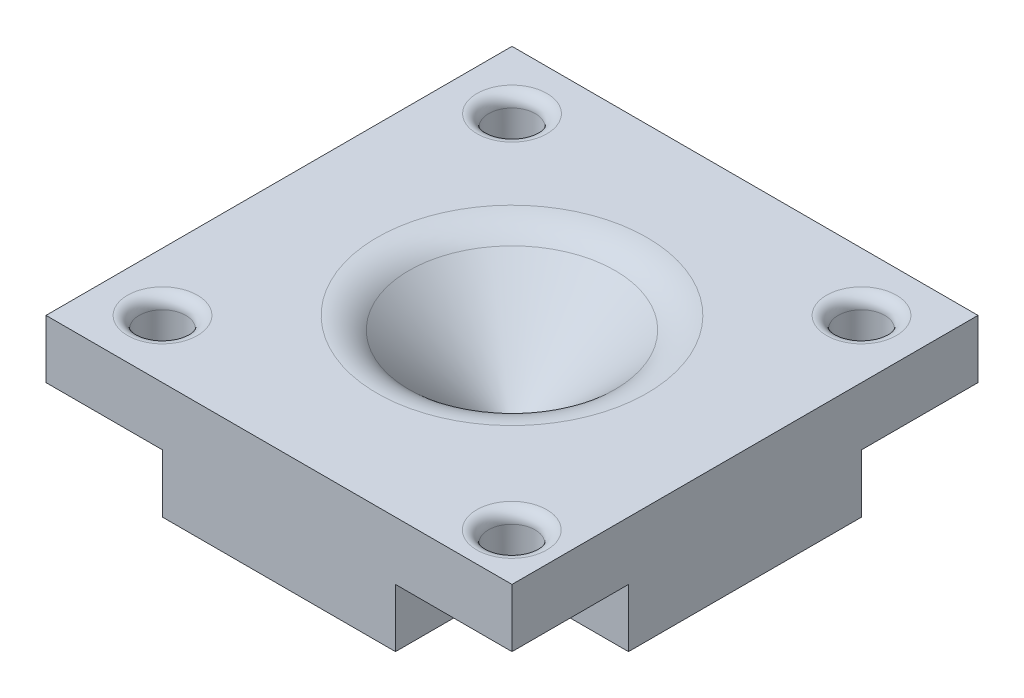
from build123d import *

# Parameters (mm, degrees)
SKETCH1_W           = 20
SKETCH1_H           = 20
BOSS_EXTRUDE1_DEPTH = 5
SKETCH4_W           = 0.5
SKETCH4_H           = 0.5
CUT_EXTRUDE1_DEPTH  = 7
FILLET1_R           = 2
SKETCH5_W           = 5
SKETCH5_H           = 5
CUT_EXTRUDE2_DEPTH  = 2.5
SKETCH6_R           = 1
CUT_EXTRUDE3_DEPTH  = 3
FILLET2_R           = 0.5


with BuildPart() as part:
    # Sketch1 → Boss-Extrude1 (new body)
    with BuildSketch(Plane(origin=(0, 0, 0), x_dir=(1, 0, 0), z_dir=(0, 1, 0))):
        with Locations((10, 10)):
            Rectangle(SKETCH1_W, SKETCH1_H)
    extrude(amount=BOSS_EXTRUDE1_DEPTH)

    # Sketch3 → Cut-Revolve3 (revolve, cut)
    with BuildSketch(Plane(origin=(10, 0, 0), x_dir=(0, 0, -1), z_dir=(1, 0, 0))):
        Polygon((10, 0.3), (10, 5), (5, 5), align=None)
    revolve(axis=Axis((10, 5, -10), (0, -1, 0)), mode=Mode.SUBTRACT)

    # Sketch4 → Cut-Extrude1 (cut)
    with BuildSketch(Plane(origin=(0, 5, 0), x_dir=(1, 0, 0), z_dir=(0, 1, 0))):
        with Locations((10, 10)):
            Rectangle(SKETCH4_W, SKETCH4_H)
    extrude(amount=-CUT_EXTRUDE1_DEPTH, mode=Mode.SUBTRACT)

    # Fillet1
    fillet1_edges = [part.edges().sort_by_distance(p)[0] for p in [
        (10, 5, -15),
    ]]
    fillet(fillet1_edges, radius=FILLET1_R)

    # Sketch5 → Cut-Extrude2 (cut)
    with BuildSketch(Plane(origin=(0, 0, 0), x_dir=(-1, 0, 0), z_dir=(0, -1, 0))):
        with Locations((-17.5, 17.5)):
            Rectangle(SKETCH5_W, SKETCH5_H)
        with Locations((-2.5, 17.5)):
            Rectangle(SKETCH5_W, SKETCH5_H)
        with Locations((-17.5, 2.5)):
            Rectangle(SKETCH5_W, SKETCH5_H)
        with Locations((-2.5, 2.5)):
            Rectangle(SKETCH5_W, SKETCH5_H)
    extrude(amount=-CUT_EXTRUDE2_DEPTH, mode=Mode.SUBTRACT)

    # Sketch6 → Cut-Extrude3 (cut)
    with BuildSketch(Plane(origin=(0, 5, 0), x_dir=(1, 0, 0), z_dir=(0, 1, 0))):
        with Locations((17.966640292, 2.023795915)):
            Circle(SKETCH6_R)
        with Locations((17.5, 17.5)):
            Circle(SKETCH6_R)
        with Locations((2.5, 17.5)):
            Circle(SKETCH6_R)
        with Locations((2.5, 2.5)):
            Circle(SKETCH6_R)
    extrude(amount=-CUT_EXTRUDE3_DEPTH, mode=Mode.SUBTRACT)

    # Fillet2
    fillet2_edges = [part.edges().sort_by_distance(p)[0] for p in [
        (16.5, 5, -17.5),
        (1.5, 5, -17.5),
        (1.5, 5, -2.5),
        (16.966640292, 5, -2.023795915),
    ]]
    fillet(fillet2_edges, radius=FILLET2_R)


solid = part.part
